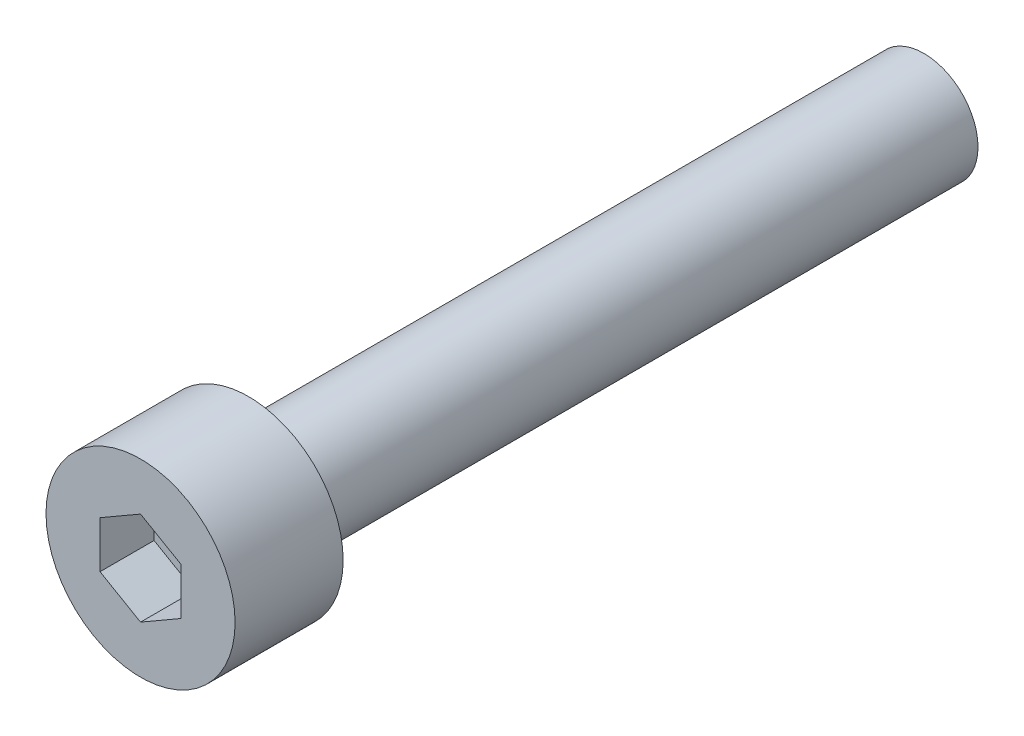
from build123d import *

# Parameters (mm, degrees)
SKETCH1_R           = 3.5
BOSS_EXTRUDE1_DEPTH = 4
CUT_EXTRUDE1_DEPTH  = 2
SKETCH3_R           = 2
BOSS_EXTRUDE2_DEPTH = 25


with BuildPart() as part:
    # Sketch1 → Boss-Extrude1 (new body)
    with BuildSketch(Plane.XY):
        Circle(SKETCH1_R)
    extrude(amount=BOSS_EXTRUDE1_DEPTH)

    # Sketch2 → Cut-Extrude1 (cut)
    with BuildSketch(Plane.XY.offset(4)):
        Polygon((0, -1.732050808), (1.5, -0.866025404), (1.5, 0.866025404), (0, 1.732050808), (-1.5, 0.866025404), (-1.5, -0.866025404), align=None)
    extrude(amount=-CUT_EXTRUDE1_DEPTH, mode=Mode.SUBTRACT)

    # Sketch3 → Boss-Extrude2 (add)
    with BuildSketch(Plane(origin=(0, 0, 0), x_dir=(-1, 0, 0), z_dir=(0, 0, -1))):
        Circle(SKETCH3_R)
    extrude(amount=BOSS_EXTRUDE2_DEPTH)


solid = part.part
